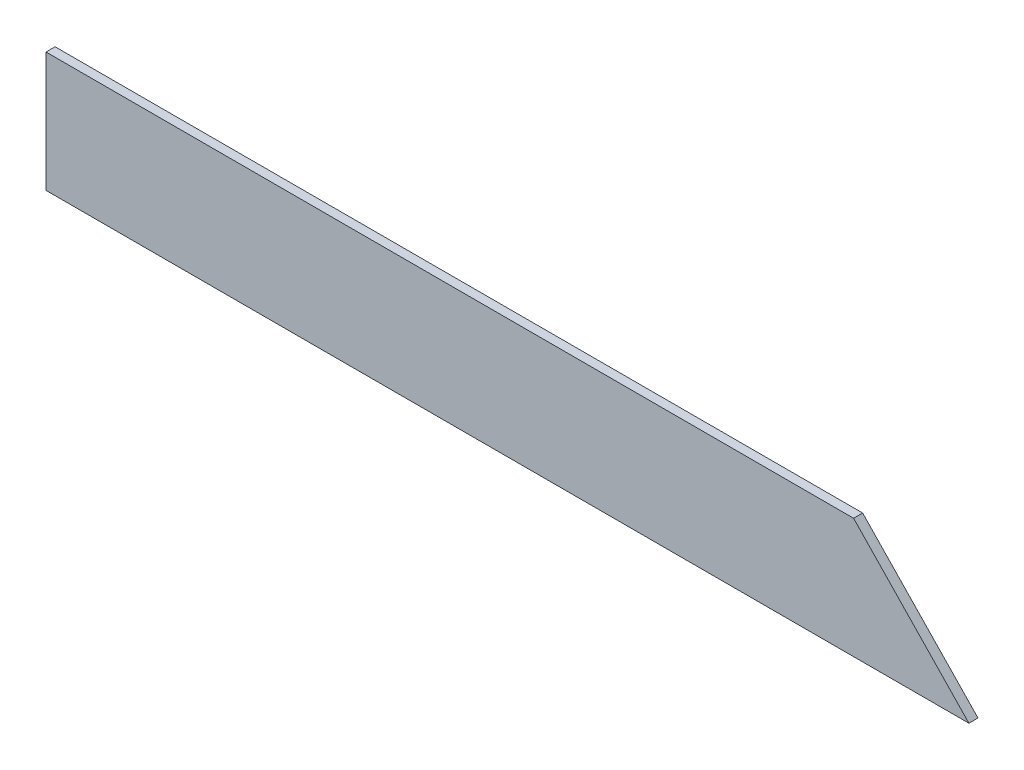
from build123d import *

# Parameters (mm, degrees)
BOSS_EXTRUDE1_DEPTH = 18.25625


with BuildPart() as part:
    # Sketch1 → Boss-Extrude1 (new body)
    with BuildSketch(Plane.XY):
        Polygon((728.361796314, 98.705513985), (496.205796314, 340.005513985), (-1129.394203686, 340.005513985), (-1129.394203686, 98.705513985), align=None)
    extrude(amount=BOSS_EXTRUDE1_DEPTH)


solid = part.part
